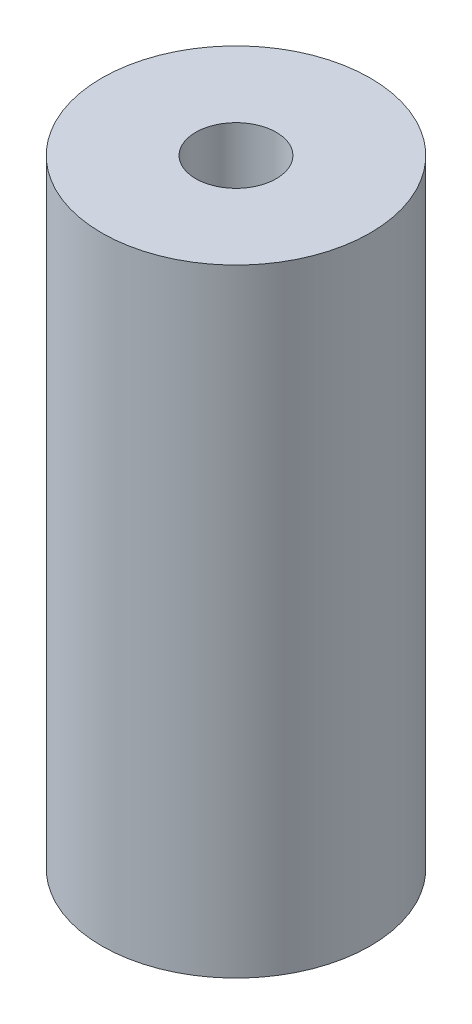
from build123d import *

# Parameters (mm, degrees)
CROQUIS1_R              = 5
SALIENTE_EXTRUIR1_DEPTH = 23
CROQUIS2_R              = 1.5
CORTAR_EXTRUIR1_DEPTH   = 5
CROQUIS4_R              = 1.5
CORTAR_EXTRUIR2_DEPTH   = 5


with BuildPart() as part:
    # Croquis1 → Saliente-Extruir1 (new body)
    with BuildSketch(Plane(origin=(0, 0, 0), x_dir=(1, 0, 0), z_dir=(0, 1, 0))):
        Circle(CROQUIS1_R)
    extrude(amount=SALIENTE_EXTRUIR1_DEPTH)

    # Croquis2 → Cortar-Extruir1 (cut)
    with BuildSketch(Plane(origin=(0, 23, 0), x_dir=(1, 0, 0), z_dir=(0, 1, 0))):
        Circle(CROQUIS2_R)
    extrude(amount=-CORTAR_EXTRUIR1_DEPTH, mode=Mode.SUBTRACT)

    # Croquis4 → Cortar-Extruir2 (cut)
    with BuildSketch(Plane.XZ):
        Circle(CROQUIS4_R)
    extrude(amount=-CORTAR_EXTRUIR2_DEPTH, mode=Mode.SUBTRACT)


solid = part.part
